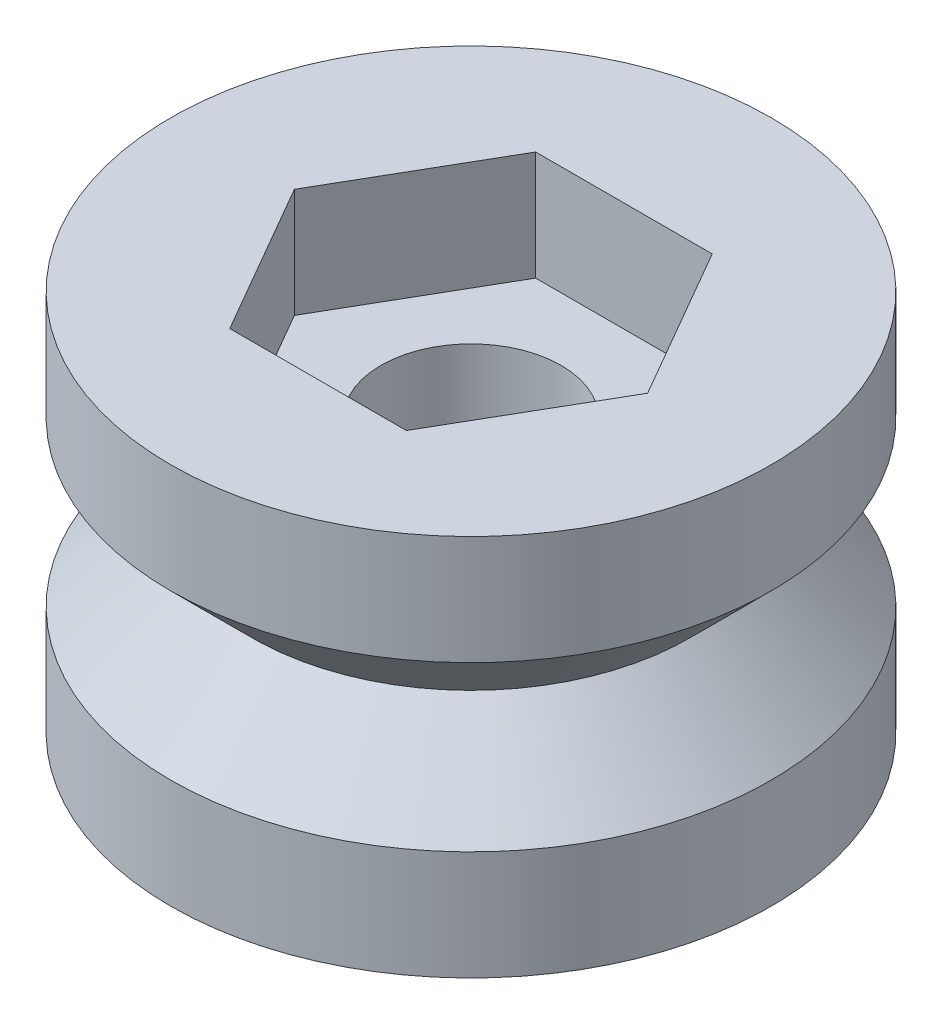
from build123d import *

# Parameters (mm, degrees)
CORTE_EXTRUS_O1_DEPTH = 2


with BuildPart() as part:
    # Esboço1 → Revolução1 (revolve)
    with BuildSketch(Plane.XY):
        Polygon((1.65, 0), (5.5, 0), (5.5, 2), (4, 3.5), (5.5, 5), (5.5, 7), (1.65, 7), align=None)
    revolve(axis=Axis((0, 0, 0), (0, 1, 0)))

    # Esboço2 → Corte-extrusão1 (cut)
    with BuildSketch(Plane(origin=(0, 7, 0), x_dir=(1, 0, 0), z_dir=(0, 1, 0))):
        Polygon((3.233161507, 0), (1.616580754, 2.8), (-1.616580754, 2.8), (-3.233161507, 0), (-1.616580754, -2.8), (1.616580754, -2.8), align=None)
    extrude(amount=-CORTE_EXTRUS_O1_DEPTH, mode=Mode.SUBTRACT)


solid = part.part
